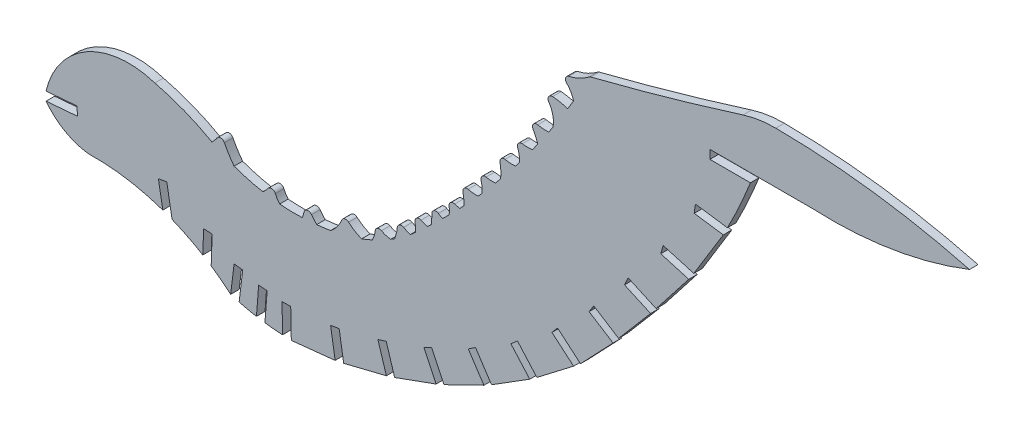
from build123d import *

# Parameters (mm, degrees)
BOSS_EXTRUDE1_DEPTH = 1.524


with BuildPart() as part:
    # Sketch1 → Boss-Extrude1 (new body)
    with BuildSketch(Plane.XY):
        with BuildLine():
            Line((42.020567794, 28.909054702), (42.020567794, 30.462108328))
            Line((42.020567794, 30.462108328), (60.209107777, 30.462108328))
            ThreePointArc((60.209107777, 30.462108328), (74.536197777, 31.261552736), (88.376179452, 35.050949317))
            ThreePointArc((88.376179452, 35.050949317), (71.230519147, 38.418003445), (53.798892328, 39.621792146))
            ThreePointArc((53.798892328, 39.621792146), (50.837763241, 39.409615442), (47.945555293, 38.739960596))
            ThreePointArc((47.945555293, 38.739960596), (34.404235518, 34.680418959), (20.752637534, 31.008758292))
            ThreePointArc((20.752637534, 31.008758292), (20.607974153, 30.95600365), (20.476870349, 30.875242652))
            ThreePointArc((20.476870349, 30.875242652), (18.7432785, 29.819762517), (16.825844077, 29.154312104))
            ThreePointArc((16.825844077, 29.154312104), (16.264365349, 28.618654401), (16.463532441, 27.868641063))
            ThreePointArc((16.463532441, 27.868641063), (17.209024695, 26.911567638), (17.678843918, 25.793078416))
            ThreePointArc((17.678843918, 25.793078416), (17.156408672, 24.916053096), (16.62787635, 24.042688577))
            ThreePointArc((16.62787635, 24.042688577), (15.299265071, 24.392254351), (13.938844163, 24.583720048))
            ThreePointArc((13.938844163, 24.583720048), (13.216737257, 24.204410853), (13.251307716, 23.389476051))
            ThreePointArc((13.251307716, 23.389476051), (13.976689652, 21.715922441), (13.999802895, 19.892073102))
            ThreePointArc((13.999802895, 19.892073102), (13.617936965, 19.313756162), (13.233340255, 18.737251659))
            ThreePointArc((13.233340255, 18.737251659), (12.251363218, 18.739500546), (11.280988023, 18.890019446))
            ThreePointArc((11.280988023, 18.890019446), (10.501174693, 18.609562957), (10.438502994, 17.783223481))
            ThreePointArc((10.438502994, 17.783223481), (10.898484717, 16.864115526), (11.292654552, 15.914919677))
            ThreePointArc((11.292654552, 15.914919677), (10.809400775, 15.233557907), (10.322270711, 14.554962021))
            ThreePointArc((10.322270711, 14.554962021), (9.422308701, 14.504241359), (8.523525176, 14.572742321))
            ThreePointArc((8.523525176, 14.572742321), (7.820356537, 14.294311704), (7.703435119, 13.547117535))
            ThreePointArc((7.703435119, 13.547117535), (7.970650153, 12.500103928), (7.993923261, 11.419780028))
            ThreePointArc((7.993923261, 11.419780028), (7.648036462, 10.968589729), (7.30040178, 10.518744765))
            ThreePointArc((7.30040178, 10.518744765), (6.360958922, 10.49194112), (5.4282561, 10.607426031))
            ThreePointArc((5.4282561, 10.607426031), (4.735323412, 10.395822054), (4.532619763, 9.700233682))
            ThreePointArc((4.532619763, 9.700233682), (4.694082643, 8.455119261), (4.647811339, 7.200432388))
            ThreePointArc((4.647811339, 7.200432388), (4.193514968, 6.651438375), (3.736554277, 6.10466004))
            ThreePointArc((3.736554277, 6.10466004), (2.888795764, 6.082966935), (2.047000755, 6.185661872))
            ThreePointArc((2.047000755, 6.185661872), (1.349109471, 5.965138383), (1.158932016, 5.258374358))
            ThreePointArc((1.158932016, 5.258374358), (1.314371078, 4.280299378), (1.311048403, 3.289955535))
            ThreePointArc((1.311048403, 3.289955535), (0.971221053, 2.906914518), (0.630057272, 2.525063339))
            ThreePointArc((0.630057272, 2.525063339), (-0.27229326, 2.540767253), (-1.161474451, 2.69516902))
            ThreePointArc((-1.161474451, 2.69516902), (-1.883893962, 2.499810445), (-2.090773942, 1.780605609))
            ThreePointArc((-2.090773942, 1.780605609), (-1.925590305, 0.785007849), (-1.898520471, -0.223836914))
            ThreePointArc((-1.898520471, -0.223836914), (-2.263100403, -0.608786349), (-2.629070764, -0.992414149))
            ThreePointArc((-2.629070764, -0.992414149), (-3.101086586, -0.91156272), (-3.562949811, -0.784999489))
            ThreePointArc((-3.562949811, -0.784999489), (-4.291061792, -0.926494168), (-4.55390822, -1.620093156))
            ThreePointArc((-4.55390822, -1.620093156), (-4.502806127, -2.287923216), (-4.544995225, -2.956375528))
            ThreePointArc((-4.544995225, -2.956375528), (-5.126185371, -3.537813553), (-5.710628375, -4.115981815))
            ThreePointArc((-5.710628375, -4.115981815), (-6.096715251, -3.915560954), (-6.468011435, -3.688909811))
            ThreePointArc((-6.468011435, -3.688909811), (-7.26139397, -3.661320038), (-7.648753096, -4.354262999))
            ThreePointArc((-7.648753096, -4.354262999), (-7.656009062, -5.218179009), (-7.74360066, -6.077673763))
            ThreePointArc((-7.74360066, -6.077673763), (-8.067037194, -6.382875199), (-8.391398453, -6.687093677))
            ThreePointArc((-8.391398453, -6.687093677), (-8.992764242, -6.513050804), (-9.574081035, -6.280666385))
            ThreePointArc((-9.574081035, -6.280666385), (-10.343727975, -6.36016986), (-10.647049674, -7.071979639))
            ThreePointArc((-10.647049674, -7.071979639), (-10.563494032, -7.85185387), (-10.515826951, -8.634741609))
            ThreePointArc((-10.515826951, -8.634741609), (-10.995344107, -9.056342773), (-11.483643856, -9.467739903))
            ThreePointArc((-11.483643856, -9.467739903), (-12.090564053, -9.232141284), (-12.672204081, -8.939645622))
            ThreePointArc((-12.672204081, -8.939645622), (-13.399328645, -8.927762473), (-13.805286544, -9.53112764))
            ThreePointArc((-13.805286544, -9.53112764), (-13.97221339, -10.539160245), (-14.276800885, -11.514465716))
            ThreePointArc((-14.276800885, -11.514465716), (-14.626844366, -11.738000467), (-14.979920764, -11.956713248))
            ThreePointArc((-14.979920764, -11.956713248), (-15.830795479, -11.785544888), (-16.630991892, -11.44943168))
            ThreePointArc((-16.630991892, -11.44943168), (-17.343138498, -11.441612311), (-17.75070309, -12.025654291))
            ThreePointArc((-17.75070309, -12.025654291), (-17.935830396, -12.884166581), (-18.270637535, -13.696090007))
            ThreePointArc((-18.270637535, -13.696090007), (-19.21708616, -14.104884044), (-20.176901984, -14.481223181))
            ThreePointArc((-20.176901984, -14.481223181), (-21.411008282, -13.883589454), (-22.513967035, -13.068932216))
            ThreePointArc((-22.513967035, -13.068932216), (-23.194466156, -12.895289276), (-23.727971895, -13.352019559))
            ThreePointArc((-23.727971895, -13.352019559), (-24.547077912, -14.792162456), (-25.716636183, -15.96565284))
            ThreePointArc((-25.716636183, -15.96565284), (-26.950342235, -16.147541089), (-28.190491017, -16.278479833))
            ThreePointArc((-28.190491017, -16.278479833), (-28.676180319, -15.758910365), (-29.124944409, -15.20713385))
            ThreePointArc((-29.124944409, -15.20713385), (-29.899086047, -14.923757047), (-30.478041488, -15.510620138))
            ThreePointArc((-30.478041488, -15.510620138), (-30.598490417, -16.00741365), (-30.749284039, -16.495853023))
            ThreePointArc((-30.749284039, -16.495853023), (-32.781962604, -16.520125144), (-34.811996508, -16.413665582))
            ThreePointArc((-34.811996508, -16.413665582), (-35.241520588, -15.828137693), (-35.579204015, -15.185250653))
            ThreePointArc((-35.579204015, -15.185250653), (-36.192042208, -14.731213766), (-36.891343495, -15.035676989))
            ThreePointArc((-36.891343495, -15.035676989), (-37.321025683, -15.551873325), (-37.807709479, -16.014717062))
            ThreePointArc((-37.807709479, -16.014717062), (-40.407578973, -15.426750157), (-42.948653639, -14.621786797))
            ThreePointArc((-42.948653639, -14.621786797), (-43.877804638, -13.284510583), (-44.678923078, -11.866822855))
            ThreePointArc((-44.678923078, -11.866822855), (-45.309737197, -11.45009897), (-45.989062046, -11.78191669))
            ThreePointArc((-45.989062046, -11.78191669), (-46.417326671, -12.348485501), (-46.89992548, -12.869550944))
            ThreePointArc((-46.89992548, -12.869550944), (-51.861950361, -10.50050401), (-57.103235993, -8.838276823))
            ThreePointArc((-57.103235993, -8.838276823), (-69.229378177, -10.059896613), (-76.538274892, -19.812624846))
            Line((-76.538274892, -19.812624846), (-71.025682939, -19.348570727))
            Line((-71.025682939, -19.348570727), (-70.902307058, -20.890620959))
            Line((-70.902307058, -20.890620959), (-76.524264194, -21.359149654))
            ThreePointArc((-76.524264194, -21.359149654), (-73.202313698, -24.298299689), (-68.997855751, -25.711272227))
            ThreePointArc((-68.997855751, -25.711272227), (-62.245119572, -26.148610844), (-55.679959716, -27.788545915))
            Line((-55.679959716, -27.788545915), (-56.466056157, -23.330371461))
            Line((-56.466056157, -23.330371461), (-54.965209142, -23.065731638))
            Line((-54.965209142, -23.065731638), (-54.023026848, -28.409112953))
            ThreePointArc((-54.023026848, -28.409112953), (-51.222206456, -29.668966033), (-48.533476606, -31.153067256))
            Line((-48.533476606, -31.153067256), (-48.392139187, -27.026013799))
            Line((-48.392139187, -27.026013799), (-46.869032096, -27.07817499))
            Line((-46.869032096, -27.07817499), (-47.041246983, -32.106850693))
            ThreePointArc((-47.041246983, -32.106850693), (-45.261248987, -33.381264951), (-43.558390625, -34.757054896))
            Line((-43.558390625, -34.757054896), (-42.948653639, -29.725374648))
            Line((-42.948653639, -29.725374648), (-41.405761673, -29.912777094))
            Line((-41.405761673, -29.912777094), (-42.046831582, -35.188404003))
            ThreePointArc((-42.046831582, -35.188404003), (-40.507615226, -35.560864283), (-38.953830838, -35.866916118))
            Line((-38.953830838, -35.866916118), (-38.567471041, -30.837432419))
            Line((-38.567471041, -30.837432419), (-37.047947917, -30.954160632))
            Line((-37.047947917, -30.954160632), (-37.443152579, -36.098783399))
            ThreePointArc((-37.443152579, -36.098783399), (-35.868506531, -36.272861818), (-34.287838183, -36.379168217))
            Line((-34.287838183, -36.379168217), (-34.390230948, -31.291925141))
            Line((-34.390230948, -31.291925141), (-32.838258334, -31.260657337))
            Line((-32.838258334, -31.260657337), (-32.732480658, -36.46942697))
            Line((-32.732480658, -36.46942697), (-24.901328639, -35.646283427))
            Line((-24.901328639, -35.646283427), (-25.716636183, -30.622945066))
            Line((-25.716636183, -30.622945066), (-24.18442354, -30.373104187))
            Line((-24.18442354, -30.373104187), (-23.378750538, -35.332565976))
            Line((-23.378750538, -35.332565976), (-15.754496075, -33.451052558))
            Line((-15.754496075, -33.451052558), (-17.268600953, -28.59357241))
            Line((-17.268600953, -28.59357241), (-15.785671292, -28.131904925))
            Line((-15.785671292, -28.131904925), (-14.276800885, -32.975753319))
            Line((-14.276800885, -32.975753319), (-6.887312945, -30.295888555))
            Line((-6.887312945, -30.295888555), (-9.062530943, -25.711272227))
            Line((-9.062530943, -25.711272227), (-7.659449029, -25.045719688))
            Line((-7.659449029, -25.045719688), (-5.460499351, -29.680509955))
            Line((-5.460499351, -29.680509955), (1.66471385, -26.206301216))
            Line((1.66471385, -26.206301216), (-1.129888696, -21.978344124))
            Line((-1.129888696, -21.978344124), (0.166946615, -21.122687904))
            Line((0.166946615, -21.122687904), (3.024909149, -25.447931035))
            Line((3.024909149, -25.447931035), (9.85214229, -21.175781189))
            Line((9.85214229, -21.175781189), (6.49245711, -17.383663186))
            Line((6.49245711, -17.383663186), (7.654751215, -16.353123639))
            Line((7.654751215, -16.353123639), (11.124086742, -20.270018068))
            Line((11.124086742, -20.270018068), (17.678843918, -15.245380599))
            Line((17.678843918, -15.245380599), (13.813073069, -11.956713248))
            Line((13.813073069, -11.956713248), (14.819601922, -10.773741239))
            Line((14.819601922, -10.773741239), (18.910877184, -14.25445498))
            Line((18.910877184, -14.25445498), (24.730651311, -8.138014433))
            Line((24.730651311, -8.138014433), (20.443894414, -5.427700026))
            Line((20.443894414, -5.427700026), (21.275788521, -4.115981815))
            Line((21.275788521, -4.115981815), (25.720223739, -6.92591683))
            Line((25.720223739, -6.92591683), (31.431956864, -0.223836914))
            Line((31.431956864, -0.223836914), (26.769230651, 1.874373589))
            Line((26.769230651, 1.874373589), (27.408768886, 3.289955535))
            Line((27.408768886, 3.289955535), (32.429872908, 1.030148499))
            Line((32.429872908, 1.030148499), (38.249089364, 8.477908825))
            Line((38.249089364, 8.477908825), (33.246451594, 9.926817282))
            Line((33.246451594, 9.926817282), (33.675296421, 11.419780028))
            Line((33.675296421, 11.419780028), (39.149232799, 9.834199055))
            Line((39.149232799, 9.834199055), (44.416009092, 18.427984302))
            Line((44.416009092, 18.427984302), (39.218755768, 19.165604458))
            Line((39.218755768, 19.165604458), (39.436245037, 20.703414914))
            Line((39.436245037, 20.703414914), (45.153439865, 19.892073102))
            ThreePointArc((45.153439865, 19.892073102), (47.322141041, 24.348745257), (49.264963759, 28.908419739))
            Line((49.264963759, 28.908419739), (42.020567794, 28.909054702))
        make_face()
    extrude(amount=BOSS_EXTRUDE1_DEPTH)


solid = part.part
